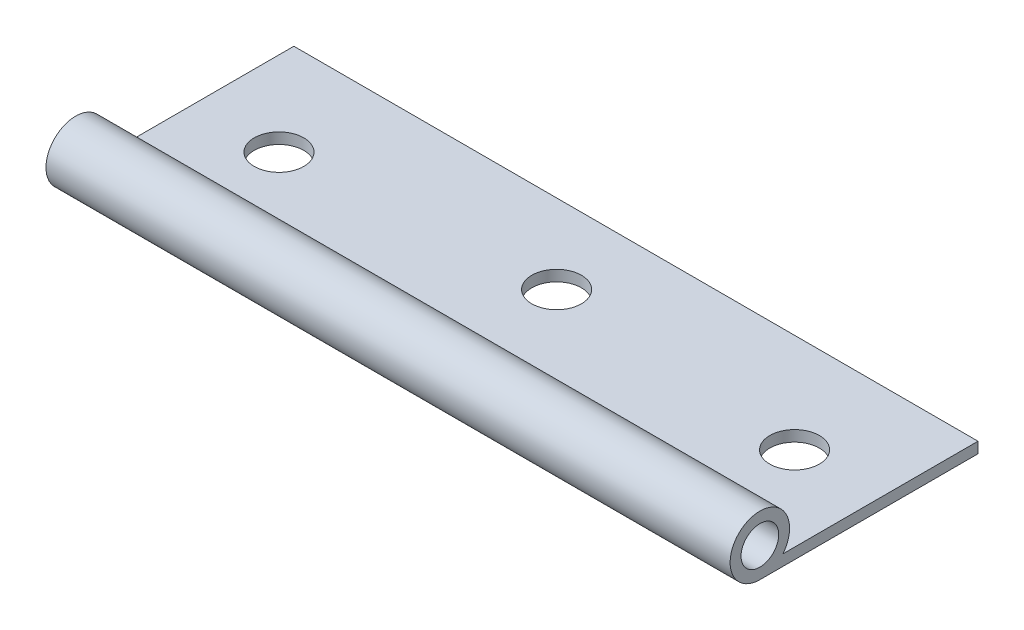
from build123d import *

# Parameters (mm, degrees)
SKETCH_1_R          = 1.9
EXTRUDE_1_DEPTH     = 69
SKETCH_2_R          = 2.5
CUT_EXTRUDE_1_DEPTH = 2.1


with BuildPart() as part:
    # 草图1 → 凸台-拉伸1 (new body)
    with BuildSketch(Plane(origin=(0, 0, 0), x_dir=(0, 0, -1), z_dir=(1, 0, 0))):
        with BuildLine():
            Line((0, 0), (19, 0))
            Line((19, 0), (19, -1.1))
            Line((19, -1.1), (0, -1.1))
            Line((0, -1.1), (-3, -1.1))
            ThreePointArc((-3, -1.1), (-4.284523258, 4.611088342), (-0.678362647, 0))
            Line((-0.678362647, 0), (0, 0))
        make_face()
        with Locations((-3, 1.9)):
            Circle(SKETCH_1_R, mode=Mode.SUBTRACT)
    extrude(amount=EXTRUDE_1_DEPTH)

    # 草图2 → 切除-拉伸1 (cut, through all)
    with BuildSketch(Plane(origin=(0, 0, 0), x_dir=(1, 0, 0), z_dir=(0, 1, 0))):
        with Locations((8.5, 9)):
            Circle(SKETCH_2_R)
        with Locations((60.5, 9)):
            Circle(SKETCH_2_R)
        with Locations((34.5, 11)):
            Circle(SKETCH_2_R)
    extrude(amount=-CUT_EXTRUDE_1_DEPTH, mode=Mode.SUBTRACT)


solid = part.part
